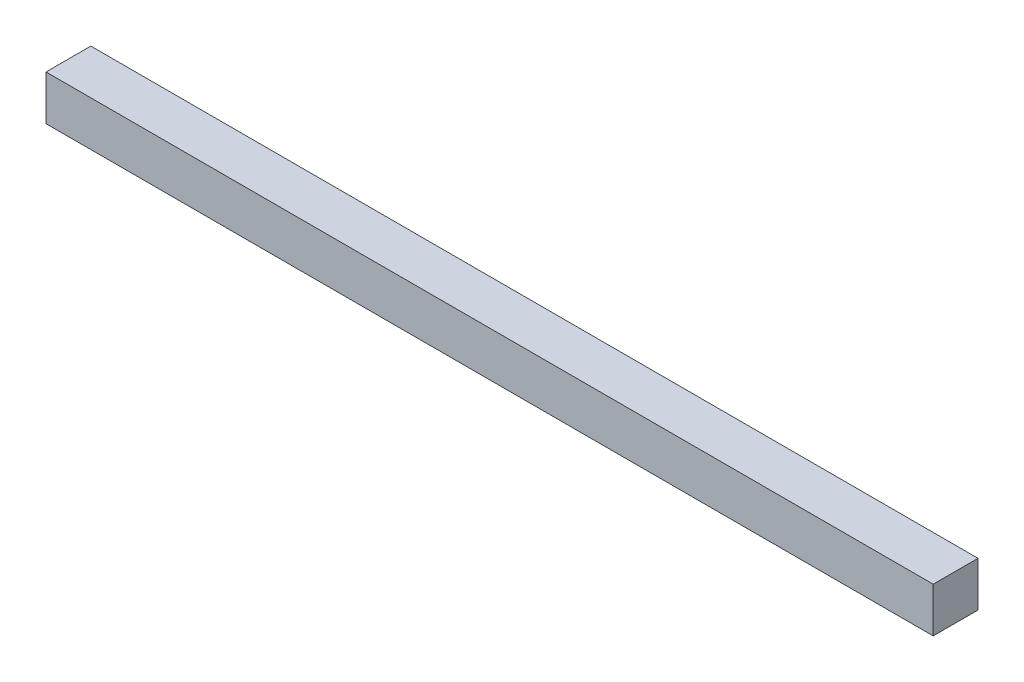
from build123d import *

# Parameters (mm, degrees)
SKETCH1_W           = 99
SKETCH1_H           = 5
BOSS_EXTRUDE1_DEPTH = 5


with BuildPart() as part:
    # Sketch1 → Boss-Extrude1 (new body)
    with BuildSketch(Plane.XY):
        Rectangle(SKETCH1_W, SKETCH1_H)
    extrude(amount=BOSS_EXTRUDE1_DEPTH)


solid = part.part
